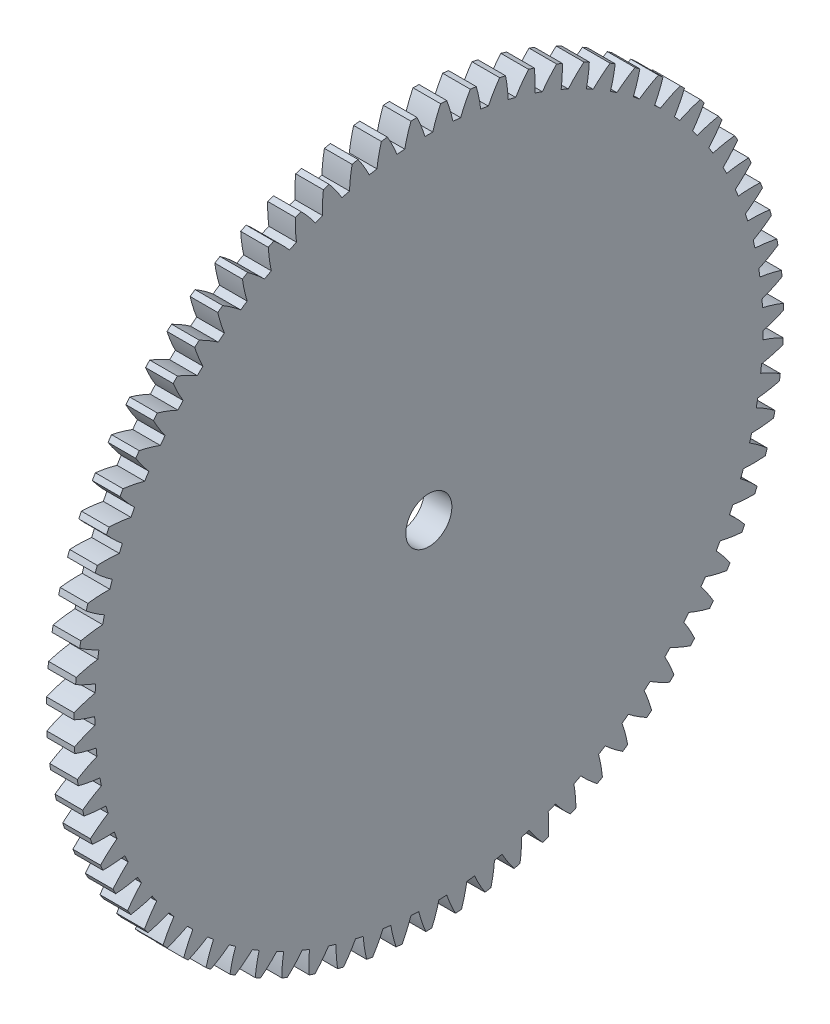
from build123d import *

# Parameters (mm, degrees)
BASPROSKE_W     = 3
BASPROSKE_H     = 38.5
TOOTHCUT_DEPTH  = 55.529808362
TEETHCUTS_COUNT = 75
TEETHCUTS_ANGLE = 355.2
BORSKE_R        = 2.5
BORE_DEPTH      = 50.0000508


with BuildPart() as part:
    # BasProSke → Base-Revolve (revolve)
    with BuildSketch(Plane(origin=(0, 0, 0), x_dir=(1, 0, 0), z_dir=(0, 1, 0)), mode=Mode.PRIVATE) as base_revolve_sk:
        with Locations((1.5, 19.25)):
            Rectangle(BASPROSKE_W, BASPROSKE_H)
    revolve(base_revolve_sk.sketch.rotate(Axis((-10, 0, 0), (1, 0, 0)), 180), axis=Axis((-10, 0, 0), (1, 0, 0)))

    # TooCutSke → ToothCut (cut, through all)
    with BuildSketch(Plane(origin=(0, 0, 0), x_dir=(0, 0, -1), z_dir=(1, 0, 0))):
        with BuildLine():
            ThreePointArc((0.422493895, 36.246537764), (0, 36.249), (-0.422493895, 36.246537764))
            ThreePointArc((-0.422493895, 36.246537764), (-0.813667594, 37.392712423), (-1.296032055, 38.503593937))
            ThreePointArc((-1.296032055, 38.503593937), (0, 38.5254), (1.296032055, 38.503593937))
            ThreePointArc((1.296032055, 38.503593937), (0.813667594, 37.392712423), (0.422493895, 36.246537764))
        make_face()
    toothcut = extrude(amount=TOOTHCUT_DEPTH, mode=Mode.SUBTRACT)

    # TeethCuts: ToothCut ×75 about axis
    teethcuts_axis = Axis((-10, 0, 0), (1, 0, 0))
    for i in range(1, TEETHCUTS_COUNT):
        add(toothcut.rotate(teethcuts_axis, i * TEETHCUTS_ANGLE / (TEETHCUTS_COUNT - 1)), mode=Mode.SUBTRACT)

    # BorSke → Bore (cut, symmetric)
    with BuildSketch(Plane(origin=(0, 0, 0), x_dir=(0, 0, -1), z_dir=(1, 0, 0))):
        with Locations(Location((0, 0, 0), (0, 0, 180))):
            Circle(BORSKE_R)
    extrude(amount=BORE_DEPTH, both=True, mode=Mode.SUBTRACT)


solid = part.part
